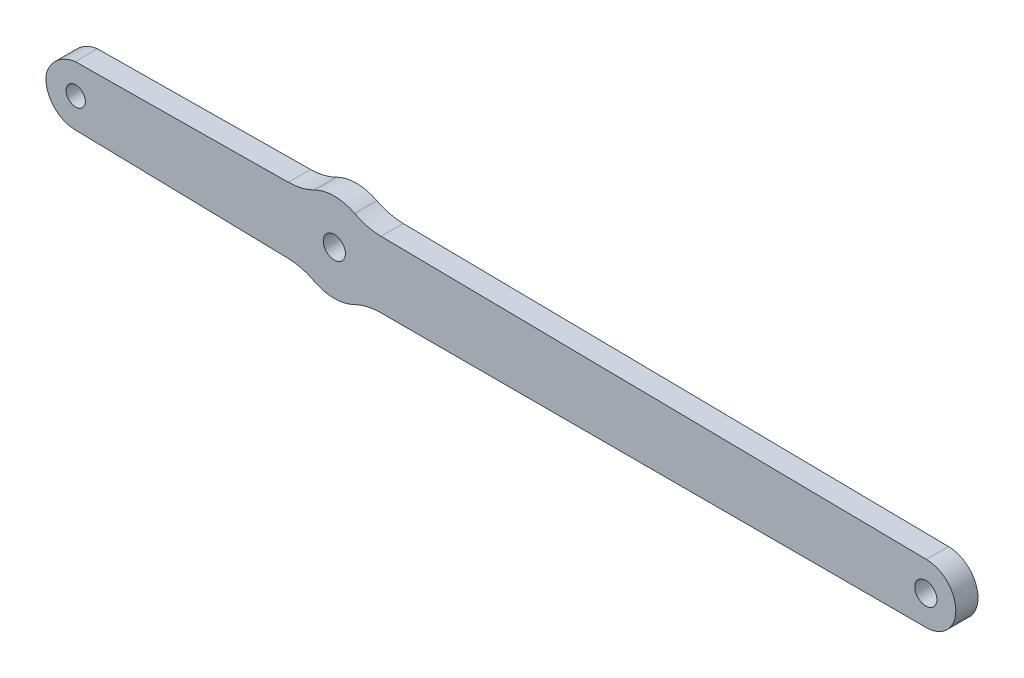
from build123d import *

# Parameters (mm, degrees)
MODEL_R             = 1.5
MODEL_R_2           = 1.3
BOSS_EXTRUDE1_DEPTH = 3


with BuildPart() as part:
    # Model → Boss-Extrude1 (new body)
    with BuildSketch(Plane.XY):
        with BuildLine():
            Line((67.038441792, 41.415856749), (104.038441639, 41.418238239))
            Line((104.038441639, 41.418238239), (108.538521807, 41.418527884))
            ThreePointArc((108.538521807, 41.418527884), (112.537988752, 45.418317376), (108.53819926, 49.417784321))
            Line((108.53819926, 49.417784321), (34.799117207, 50.383081783))
            ThreePointArc((34.799117207, 50.383081783), (32.966554958, 50.620533228), (31.23734869, 51.272080055))
            ThreePointArc((31.23734869, 51.272080055), (28.515998073, 51.939320982), (25.788421234, 51.298006533))
            ThreePointArc((25.788421234, 51.298006533), (24.076314539, 50.668969798), (22.266330888, 50.443236041))
            Line((22.266330888, 50.443236041), (-6.550050988, 50.167207177))
            ThreePointArc((-6.550050988, 50.167207177), (-8.973297656, 49.093954733), (-10.445895761, 46.890446157))
            ThreePointArc((-10.445895761, 46.890446157), (-9.613967932, 43.642213171), (-6.602156551, 42.168403941))
            Line((-6.602156551, 42.168403941), (22.208184202, 41.516932419))
            ThreePointArc((22.208184202, 41.516932419), (24.01842496, 41.280561161), (25.718896078, 40.616301461))
            ThreePointArc((25.718896078, 40.616301461), (28.43787871, 39.93957832), (31.167673514, 40.571275311))
            ThreePointArc((31.167673514, 40.571275311), (32.905215524, 41.200228691), (34.740707643, 41.413777918))
            Line((34.740707643, 41.413777918), (46.038441879, 41.414505092))
            Line((46.038441879, 41.414505092), (56.538441836, 41.415180921))
            Line((56.538441836, 41.415180921), (67.038441792, 41.415856749))
        make_face()
        with Locations((28.487510706, 45.939417458)):
            Circle(MODEL_R, mode=Mode.SUBTRACT)
        with Locations((108.485791619, 45.418177884)):
            Circle(MODEL_R, mode=Mode.SUBTRACT)
        with Locations((-6.485524229, 46.174255041)):
            Circle(MODEL_R_2, mode=Mode.SUBTRACT)
    extrude(amount=BOSS_EXTRUDE1_DEPTH)


solid = part.part
